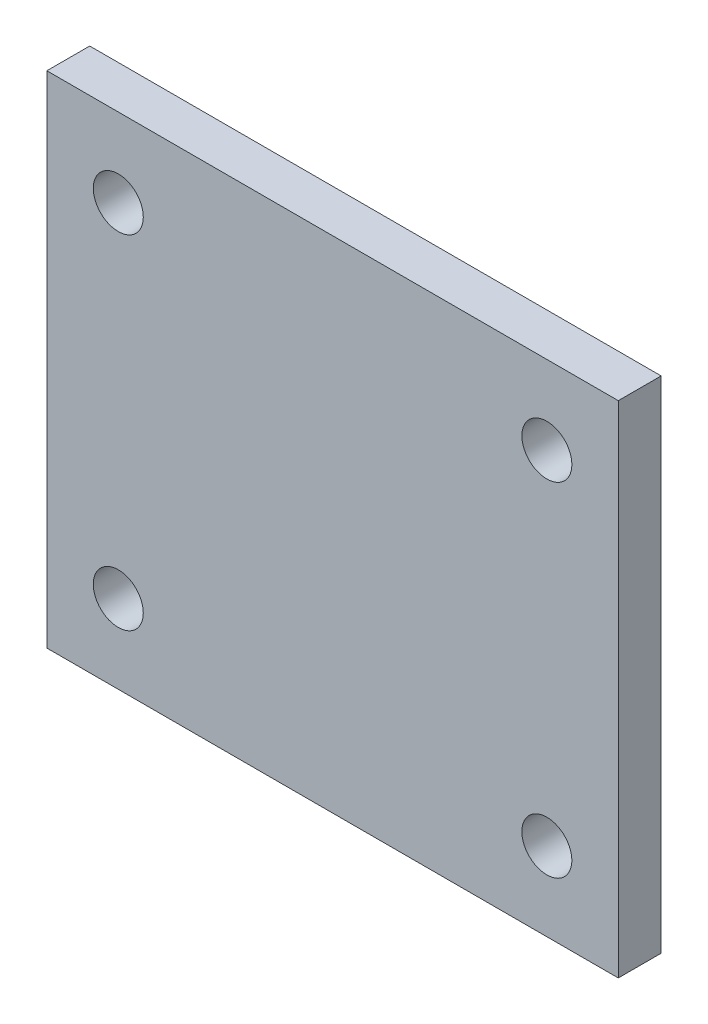
from build123d import *

# Parameters (mm, degrees)
SKETCH1_W           = 40
SKETCH1_H           = 35
SKETCH1_R           = 1.75
BOSS_EXTRUDE1_DEPTH = 3


with BuildPart() as part:
    # Sketch1 → Boss-Extrude1 (new body)
    with BuildSketch(Plane.XY):
        with Locations((20, 17.5)):
            Rectangle(SKETCH1_W, SKETCH1_H)
        with Locations((5, 29.5)):
            Circle(SKETCH1_R, mode=Mode.SUBTRACT)
        with Locations((5, 5.5)):
            Circle(SKETCH1_R, mode=Mode.SUBTRACT)
        with Locations((35, 5.5)):
            Circle(SKETCH1_R, mode=Mode.SUBTRACT)
        with Locations((35, 29.5)):
            Circle(SKETCH1_R, mode=Mode.SUBTRACT)
    extrude(amount=BOSS_EXTRUDE1_DEPTH)


solid = part.part
